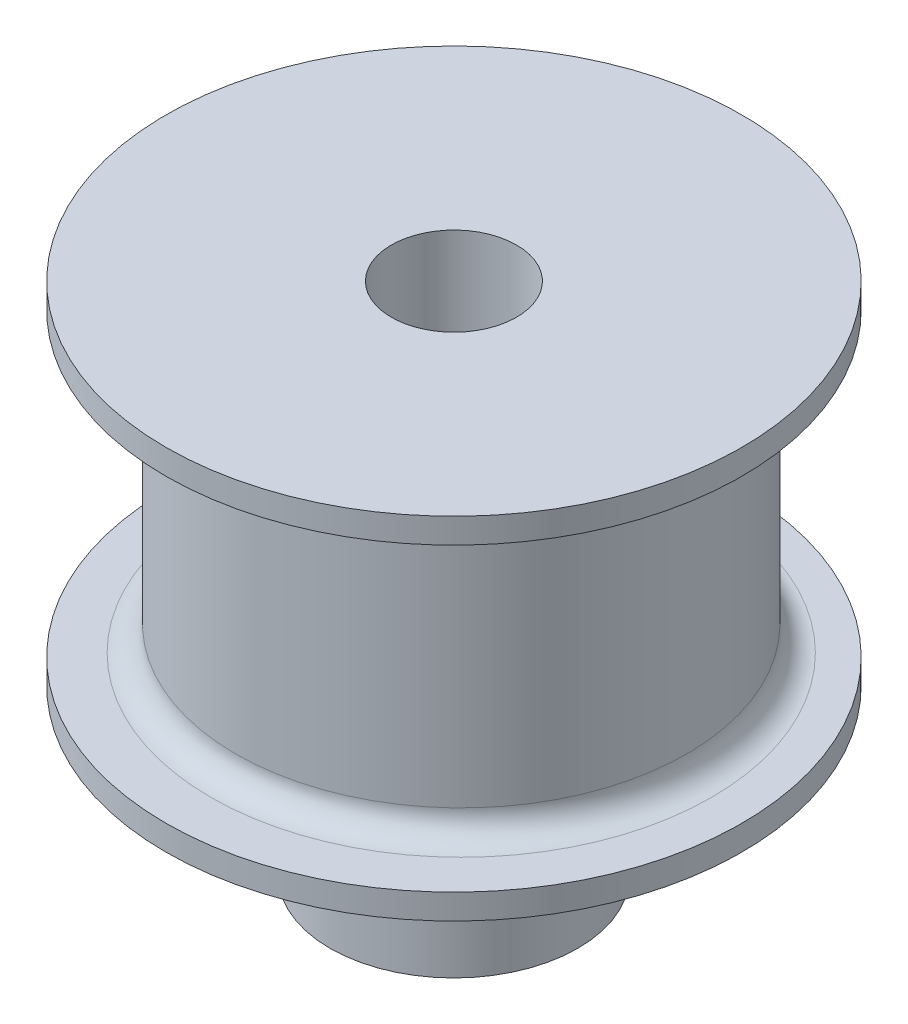
from build123d import *

# Parameters (mm, degrees)
SKETCH1_R           = 4.95
BOSS_EXTRUDE2_DEPTH = 6.6
SKETCH4_R           = 11.5
BOSS_EXTRUDE3_DEPTH = 1
SKETCH5_R           = 9
BOSS_EXTRUDE4_DEPTH = 12
SKETCH6_R           = 11.5
BOSS_EXTRUDE5_DEPTH = 1
FILLET1_R           = 1
FILLET2_R           = 1
SKETCH7_R           = 2.5
CUT_EXTRUDE1_DEPTH  = 21.6


with BuildPart() as part:
    # Sketch1 → Boss-Extrude2 (new body)
    with BuildSketch(Plane(origin=(0, 0, 0), x_dir=(1, 0, 0), z_dir=(0, 1, 0))):
        Circle(SKETCH1_R)
    extrude(amount=BOSS_EXTRUDE2_DEPTH)

    # Sketch4 → Boss-Extrude3 (add)
    with BuildSketch(Plane(origin=(0, 6.6, 0), x_dir=(1, 0, 0), z_dir=(0, 1, 0))):
        Circle(SKETCH4_R)
    extrude(amount=BOSS_EXTRUDE3_DEPTH)

    # Sketch5 → Boss-Extrude4 (add)
    with BuildSketch(Plane(origin=(0, 7.6, 0), x_dir=(1, 0, 0), z_dir=(0, 1, 0))):
        with Locations((0, 0.291114712)):
            Circle(SKETCH5_R)
    extrude(amount=BOSS_EXTRUDE4_DEPTH)

    # Sketch6 → Boss-Extrude5 (add)
    with BuildSketch(Plane(origin=(0, 19.6, 0), x_dir=(1, 0, 0), z_dir=(0, 1, 0))):
        Circle(SKETCH6_R)
    extrude(amount=BOSS_EXTRUDE5_DEPTH)

    # Fillet1
    fillet1_edges = [part.edges().sort_by_distance(p)[0] for p in [
        (-9, 7.6, -0.291114712),
    ]]
    fillet(fillet1_edges, radius=FILLET1_R)

    # Fillet2
    fillet2_edges = [part.edges().sort_by_distance(p)[0] for p in [
        (-9, 19.6, -0.291114712),
    ]]
    fillet(fillet2_edges, radius=FILLET2_R)

    # Sketch7 → Cut-Extrude1 (cut, through all)
    with BuildSketch(Plane.XZ):
        Circle(SKETCH7_R)
    extrude(amount=-CUT_EXTRUDE1_DEPTH, mode=Mode.SUBTRACT)


solid = part.part
